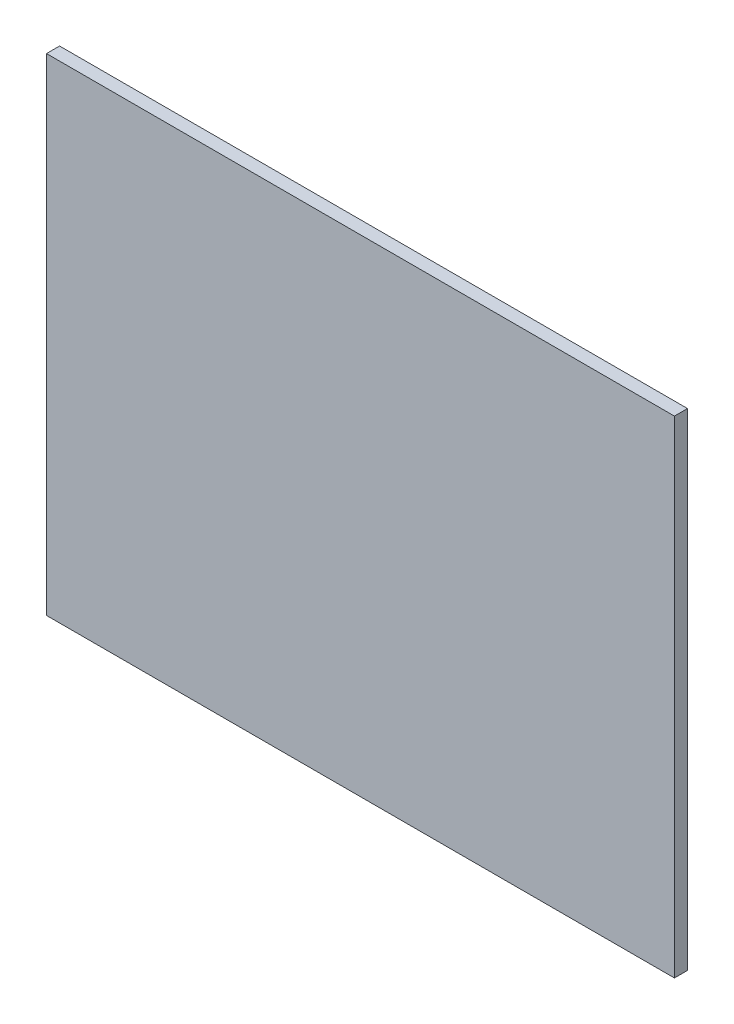
from build123d import *

# Parameters (mm, degrees)
SKETCH1_W           = 152.4
SKETCH1_H           = 118.11
BOSS_EXTRUDE1_DEPTH = 3.175


with BuildPart() as part:
    # Sketch1 → Boss-Extrude1 (new body)
    with BuildSketch(Plane.XY):
        with Locations((-1.259504132, -21.112438017)):
            Rectangle(SKETCH1_W, SKETCH1_H)
    extrude(amount=BOSS_EXTRUDE1_DEPTH)


solid = part.part
